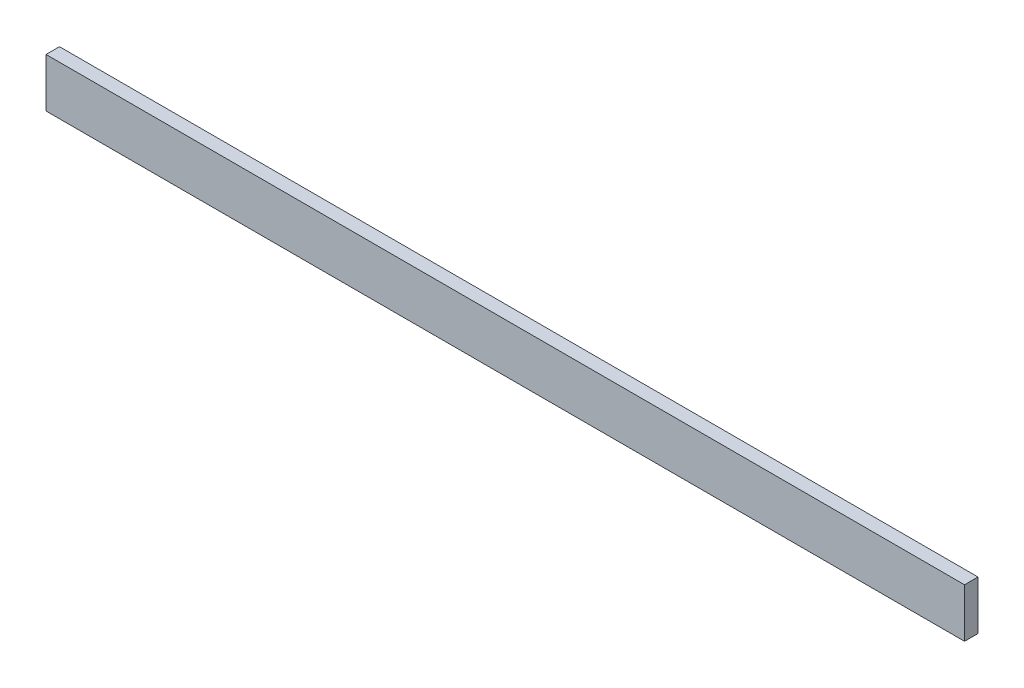
from build123d import *

# Parameters (mm, degrees)
ESQUISSE1_W      = 1500
ESQUISSE1_H      = 80
EXTRUSION1_DEPTH = 22


with BuildPart() as part:
    # Esquisse1 → Extrusion1 (new body)
    with BuildSketch(Plane.XY):
        with Locations((750, 40)):
            Rectangle(ESQUISSE1_W, ESQUISSE1_H)
    extrude(amount=EXTRUSION1_DEPTH)


solid = part.part
